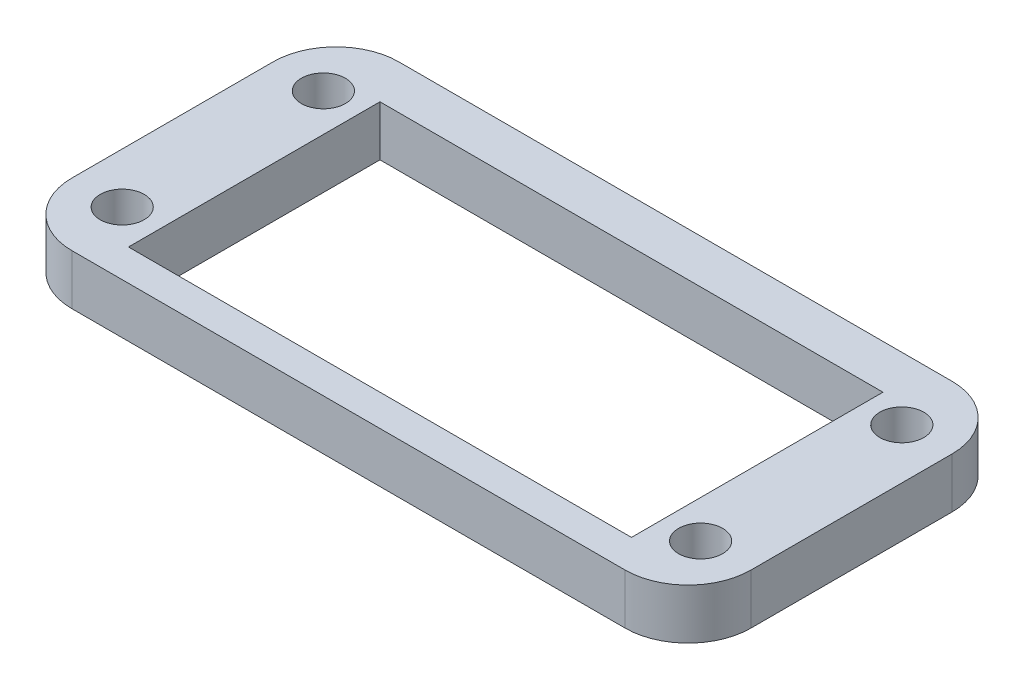
from build123d import *

# Parameters (mm, degrees)
SKETCH_1_R      = 1.75
SKETCH_1_W      = 40
SKETCH_1_H      = 20
EXTRUDE_1_DEPTH = 4


with BuildPart() as part:
    # 草图1 → 凸台-拉伸1 (new body)
    with BuildSketch(Plane(origin=(0, 0, 0), x_dir=(1, 0, 0), z_dir=(0, 1, 0))):
        with BuildLine():
            Line((-22, 13), (22, 13))
            ThreePointArc((22, 13), (25.535533906, 11.535533906), (27, 8))
            Line((27, 8), (27, -8))
            ThreePointArc((27, -8), (25.535533906, -11.535533906), (22, -13))
            Line((22, -13), (-22, -13))
            ThreePointArc((-22, -13), (-25.535533906, -11.535533906), (-27, -8))
            Line((-27, -8), (-27, 8))
            ThreePointArc((-27, 8), (-25.535533906, 11.535533906), (-22, 13))
        make_face()
        with Locations((-23, -8)):
            Circle(SKETCH_1_R, mode=Mode.SUBTRACT)
        with Locations((-23, 8)):
            Circle(SKETCH_1_R, mode=Mode.SUBTRACT)
        with Locations((23, 8)):
            Circle(SKETCH_1_R, mode=Mode.SUBTRACT)
        with Locations((23, -8)):
            Circle(SKETCH_1_R, mode=Mode.SUBTRACT)
        with Locations((0, -0.5)):
            Rectangle(SKETCH_1_W, SKETCH_1_H, mode=Mode.SUBTRACT)
    extrude(amount=EXTRUDE_1_DEPTH)


solid = part.part
